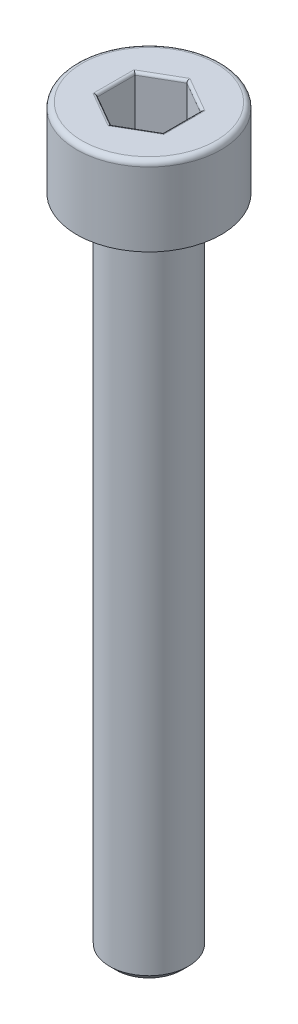
from build123d import *

# Parameters (mm, degrees)
CHAMFER1_SIZE      = 0.25
FILLET1_R          = 0.2
CUT_EXTRUDE1_DEPTH = 2
FILLET2_R          = 0.1


with BuildPart() as part:
    # Sketch1 → Revolve1 (revolve)
    with BuildSketch(Plane.XY):
        Polygon((0, -28), (-1.5, -28), (-1.5, -3), (-2.75, -3), (-2.75, 0), (0, 0), align=None)
    revolve(axis=Axis((0, 0, 0), (0, -1, 0)))

    # Chamfer1
    chamfer1_edges = [part.edges().sort_by_distance(p)[0] for p in [
        (1.5, -3, 0),
        (1.5, -28, 0),
    ]]
    chamfer(chamfer1_edges, length=CHAMFER1_SIZE)

    # Fillet1
    fillet1_edges = [part.edges().sort_by_distance(p)[0] for p in [
        (2.75, 0, 0),
    ]]
    fillet(fillet1_edges, radius=FILLET1_R)

    # Sketch2 → Cut-Extrude1 (cut)
    with BuildSketch(Plane(origin=(0, 0, 0), x_dir=(1, 0, 0), z_dir=(0, 1, 0))):
        Polygon((0, 1.443375673), (-1.25, 0.721687836), (-1.25, -0.721687836), (0, -1.443375673), (1.25, -0.721687836), (1.25, 0.721687836), align=None)
    extrude(amount=-CUT_EXTRUDE1_DEPTH, mode=Mode.SUBTRACT)

    # Fillet2
    fillet2_edges = [part.edges().sort_by_distance(p)[0] for p in [
        (0.625, -2, -1.082531755),
        (1.25, -2, 0),
        (0.625, -2, 1.082531755),
        (-0.625, -2, 1.082531755),
        (-1.25, -2, 0),
        (-0.625, -2, -1.082531755),
        (0.625, 0, -1.082531755),
        (-0.625, 0, -1.082531755),
        (-1.25, 0, 0),
        (-0.625, 0, 1.082531755),
        (0.625, 0, 1.082531755),
        (1.25, 0, 0),
    ]]
    fillet(fillet2_edges, radius=FILLET2_R)


solid = part.part
